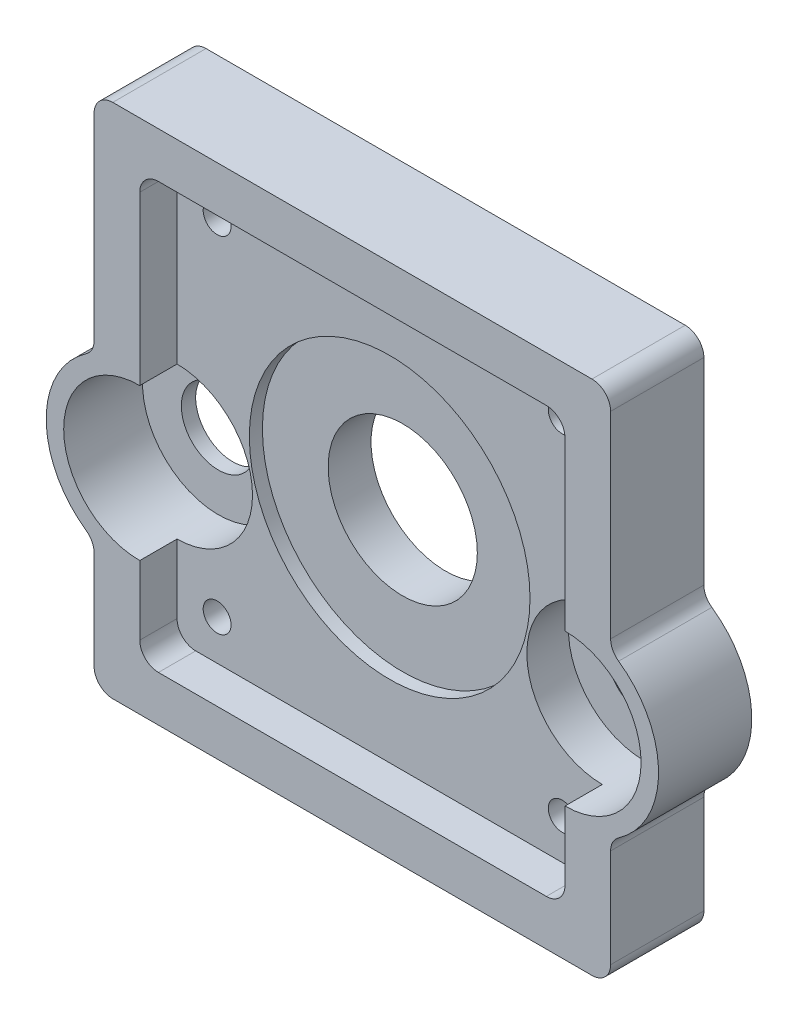
from build123d import *

# Parameters (mm, degrees)
BOSS_EXTRUDE1_DEPTH                                  = 12.7
SKETCH16_R                                           = 10.16
CUT_EXTRUDE3_DEPTH                                   = 1
CUT_EXTRUDE3_DEPTH_BACK                              = 13.7
SKETCH17_W                                           = 57.912
SKETCH17_H                                           = 57.912
CUT_EXTRUDE4_DEPTH                                   = 5.08
CBORE_FOR_3_8_BINDING_HEAD_MACHINE_SCREW_D           = 10.0838
CBORE_FOR_3_8_BINDING_HEAD_MACHINE_SCREW_CBORE_D     = 20.6375
CBORE_FOR_3_8_BINDING_HEAD_MACHINE_SCREW_CBORE_DEPTH = 10.7442
FILLET3_R                                            = 2.54
TAP_DRILL_FOR_10_24_TAP1_D                           = 3.7973
SKETCH24_R                                           = 19.1135
CUT_EXTRUDE5_DEPTH                                   = 1.778
FILLET4_R                                            = 2.54


with BuildPart() as part:
    # Sketch1 → Boss-Extrude1 (new body)
    with BuildSketch(Plane.XY):
        with BuildLine():
            Line((-35.173578353, -35.173578353), (35.173578353, -35.173578353))
            Line((35.173578353, -35.173578353), (35.173578353, -17.806510321))
            ThreePointArc((35.173578353, -17.806510321), (41.7, -6.708000046), (35.173578353, 4.390510229))
            Line((35.173578353, 4.390510229), (35.173578353, 35.173578353))
            Line((35.173578353, 35.173578353), (-35.173578353, 35.173578353))
            Line((-35.173578353, 35.173578353), (-35.173578353, 4.390510229))
            ThreePointArc((-35.173578353, 4.390510229), (-41.7, -6.708000046), (-35.173578353, -17.806510321))
            Line((-35.173578353, -17.806510321), (-35.173578353, -35.173578353))
        make_face()
    extrude(amount=BOSS_EXTRUDE1_DEPTH)

    # Sketch16 → Cut-Extrude3 (cut, two sides)
    with BuildSketch(Plane.XY.offset(12.7)) as cut_extrude3_sk:
        Circle(SKETCH16_R)
    extrude(amount=CUT_EXTRUDE3_DEPTH, mode=Mode.SUBTRACT)
    extrude(cut_extrude3_sk.sketch, amount=-CUT_EXTRUDE3_DEPTH_BACK, mode=Mode.SUBTRACT)

    # Sketch17 → Cut-Extrude4 (cut)
    with BuildSketch(Plane.XY.offset(12.7)):
        Rectangle(SKETCH17_W, SKETCH17_H)
    extrude(amount=-CUT_EXTRUDE4_DEPTH, mode=Mode.SUBTRACT)

    # CBORE for 3/8 Binding Head Machine Screw1 (through all)
    with Locations(Plane.XY.offset(12.7)):
        with Locations((-29, -6.708000046), (29, -6.708000046)):
            CounterBoreHole(CBORE_FOR_3_8_BINDING_HEAD_MACHINE_SCREW_D / 2, CBORE_FOR_3_8_BINDING_HEAD_MACHINE_SCREW_CBORE_D / 2, CBORE_FOR_3_8_BINDING_HEAD_MACHINE_SCREW_CBORE_DEPTH)

    # Fillet3
    fillet3_edges = [part.edges().sort_by_distance(p)[0] for p in [
        (35.173578353, -35.173578353, 6.35),
        (-35.173578353, -35.173578353, 6.35),
        (-35.173578353, 35.173578353, 6.35),
        (35.173578353, 35.173578353, 6.35),
        (28.956, 28.956, 10.16),
        (28.956, -28.956, 10.16),
        (-28.956, -28.956, 10.16),
        (-28.956, 28.956, 10.16),
    ]]
    fillet(fillet3_edges, radius=FILLET3_R)

    # Tap Drill for #10-24 Tap1 (through all)
    with Locations(Plane.XY.offset(7.62)):
        with Locations((-23.5, -23.5), (-23.5, 23.5), (23.5, 23.5), (23.5, -23.5)):
            Hole(TAP_DRILL_FOR_10_24_TAP1_D / 2)

    # Sketch24 → Cut-Extrude5 (cut)
    with BuildSketch(Plane.XY.offset(7.62)):
        Circle(SKETCH24_R)
    extrude(amount=-CUT_EXTRUDE5_DEPTH, mode=Mode.SUBTRACT)

    # Fillet4
    fillet4_edges = [part.edges().sort_by_distance(p)[0] for p in [
        (35.173578353, 4.390510229, 6.35),
        (35.173578353, -17.806510321, 6.35),
        (-35.173578353, -17.806510321, 6.35),
        (-35.173578353, 4.390510229, 6.35),
    ]]
    fillet(fillet4_edges, radius=FILLET4_R)


solid = part.part
